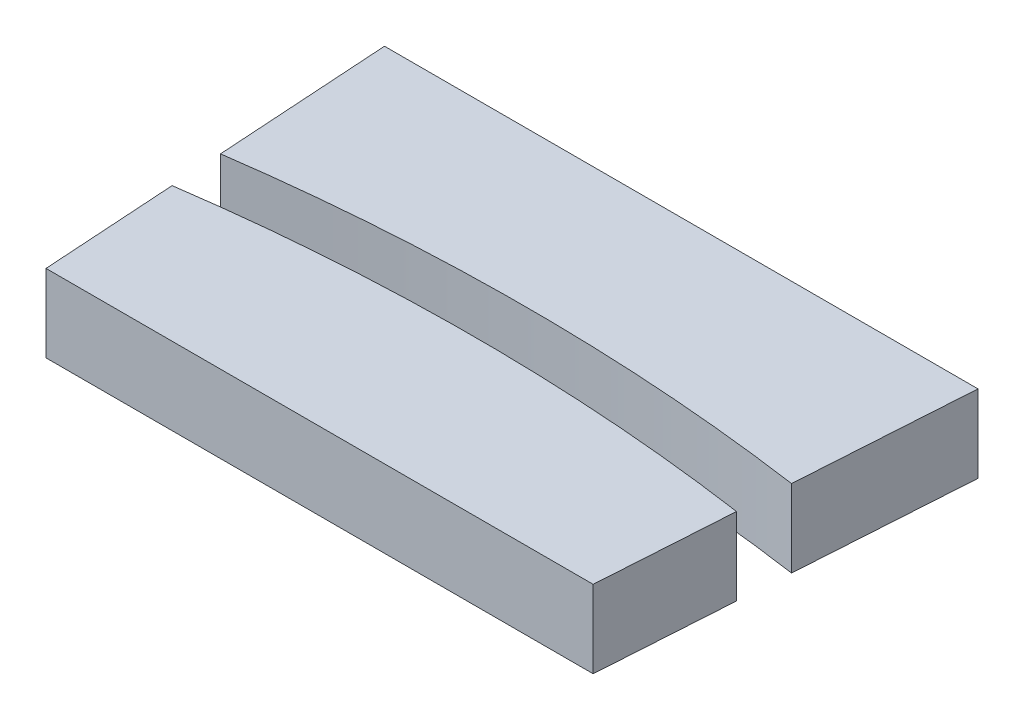
from build123d import *

# Parameters (mm, degrees)
BOSS_EXTRUDE1_DEPTH     = 3
CUT_EXTRUDE4_DEPTH      = 1
CUT_EXTRUDE4_DEPTH_BACK = 4
CUT_EXTRUDE5_DEPTH      = 1
CUT_EXTRUDE5_DEPTH_BACK = 4


with BuildPart() as part:
    # Sketch1 → Boss-Extrude1 (new body)
    with BuildSketch(Plane(origin=(0, 0, 0), x_dir=(1, 0, 0), z_dir=(0, 1, 0))):
        Polygon((-12, 92.5), (0, 92.5), (0, 62.5), (-10.077512647, 62.5), align=None)
    boss_extrude1 = extrude(amount=BOSS_EXTRUDE1_DEPTH)

    # Mirror1: Boss-Extrude1 across plane
    add(boss_extrude1.mirror(Plane(origin=(0, 0, 0), x_dir=(0, 0, 1), z_dir=(1, 0, 0))))

    # Sketch6 → Cut-Extrude4 (cut, two sides)
    with BuildSketch(Plane(origin=(0, 3, 0), x_dir=(1, 0, 0), z_dir=(0, 1, 0))) as cut_extrude4_sk:
        Polygon((-10.590175941, 70.5), (10.590175941, 70.5), (10.077512647, 62.5), (-10.077512647, 62.5), align=None)
        Polygon((11.487336706, 84.5), (-11.487336706, 84.5), (-12, 92.5), (12, 92.5), align=None)
    extrude(amount=CUT_EXTRUDE4_DEPTH, mode=Mode.SUBTRACT)
    extrude(cut_extrude4_sk.sketch, amount=-CUT_EXTRUDE4_DEPTH_BACK, mode=Mode.SUBTRACT)

    # Sketch7 → Cut-Extrude5 (cut, two sides)
    with BuildSketch(Plane(origin=(0, 3, 0), x_dir=(1, 0, 0), z_dir=(0, 1, 0))) as cut_extrude5_sk:
        with BuildLine():
            Line((-11.198534807, 77.697122329), (-10.924429943, 75.71596153))
            ThreePointArc((-10.924429943, 75.71596153), (0, 76.5), (10.924429943, 75.71596153))
            Line((10.924429943, 75.71596153), (11.052726282, 77.717998184))
            ThreePointArc((11.052726282, 77.717998184), (-0.073647687, 78.499965452), (-11.198534807, 77.697122329))
        make_face()
    extrude(amount=CUT_EXTRUDE5_DEPTH, mode=Mode.SUBTRACT)
    extrude(cut_extrude5_sk.sketch, amount=-CUT_EXTRUDE5_DEPTH_BACK, mode=Mode.SUBTRACT)


solid = part.part
